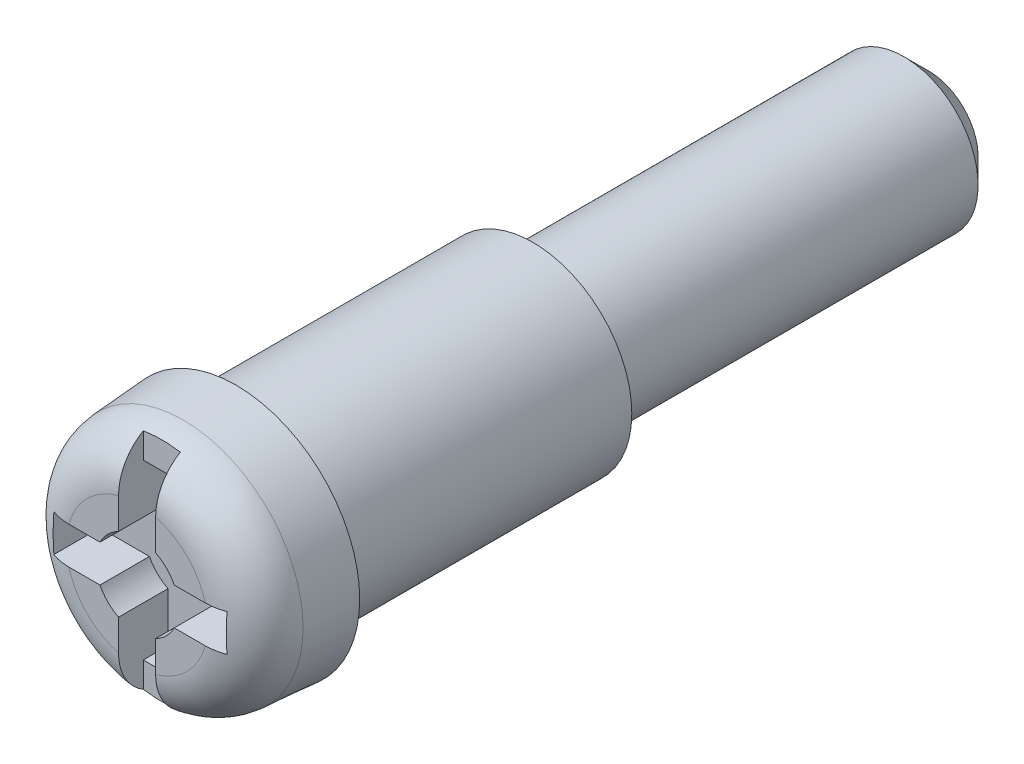
from build123d import *

# Parameters (mm, degrees)
ESQUISSE1_R             = 2.5
BASE_EXTRUSION_DEPTH    = 2
BASE_EXTRUSION_TAPER    = 4
CONG_1_R                = 1
ESQUISSE2_R             = 2
BOSS_EXTRU_1_DEPTH      = 6
ESQUISSE3_R             = 1.5
BOSS_EXTRU_2_DEPTH      = 8
CHANFREIN1_SIZE         = 0.5
ENL_V_MAT_EXTRU_1_DEPTH = 1
ESQUISSE5_W             = 0.75
ESQUISSE5_H             = 5.593358395
ENL_V_MAT_EXTRU_2_DEPTH = 0.5


with BuildPart() as part:
    # Esquisse1 → Base-Extrusion (new body)
    with BuildSketch(Plane.XY):
        Circle(ESQUISSE1_R)
    extrude(amount=BASE_EXTRUSION_DEPTH, taper=BASE_EXTRUSION_TAPER)

    # Congé1
    cong_1_edges = [part.edges().sort_by_distance(p)[0] for p in [
        (-2.360146376, 0, 2),
    ]]
    fillet(cong_1_edges, radius=CONG_1_R)

    # Esquisse2 → Boss.-Extru.1 (add)
    with BuildSketch(Plane(origin=(0, 0, 0), x_dir=(-1, 0, 0), z_dir=(0, 0, -1))):
        Circle(ESQUISSE2_R)
    extrude(amount=BOSS_EXTRU_1_DEPTH)

    # Esquisse3 → Boss.-Extru.2 (add)
    with BuildSketch(Plane(origin=(0, 0, -6), x_dir=(-1, 0, 0), z_dir=(0, 0, -1))):
        Circle(ESQUISSE3_R)
    extrude(amount=BOSS_EXTRU_2_DEPTH)

    # Chanfrein1
    chanfrein1_edges = [part.edges().sort_by_distance(p)[0] for p in [
        (1.5, 0, -14),
    ]]
    chamfer(chanfrein1_edges, length=CHANFREIN1_SIZE)

    # Esquisse4 → Enlèv. mat.-Extru.1 (cut)
    with BuildSketch(Plane.XY.offset(2)):
        with BuildLine():
            Line((-1.75, -0.375), (-0.75, -0.375))
            ThreePointArc((-0.75, -0.375), (-0.592927061, -0.592927061), (-0.375, -0.75))
            Line((-0.375, -0.75), (-0.375, -1.75))
            Line((-0.375, -1.75), (0.375, -1.75))
            Line((0.375, -1.75), (0.375, -0.75))
            ThreePointArc((0.375, -0.75), (0.592927061, -0.592927061), (0.75, -0.375))
            Line((0.75, -0.375), (1.75, -0.375))
            Line((1.75, -0.375), (1.75, 0.375))
            Line((1.75, 0.375), (0.75, 0.375))
            ThreePointArc((0.75, 0.375), (0.592927061, 0.592927061), (0.375, 0.75))
            Line((0.375, 0.75), (0.375, 1.75))
            Line((0.375, 1.75), (-0.375, 1.75))
            Line((-0.375, 1.75), (-0.375, 0.75))
            ThreePointArc((-0.375, 0.75), (-0.592927061, 0.592927061), (-0.75, 0.375))
            Line((-0.75, 0.375), (-1.75, 0.375))
            Line((-1.75, 0.375), (-1.75, -0.375))
        make_face()
    extrude(amount=-ENL_V_MAT_EXTRU_1_DEPTH, mode=Mode.SUBTRACT)

    # Esquisse5 → Enlèv. mat.-Extru.2 (cut)
    with BuildSketch(Plane.XY.offset(2)):
        with Locations((0, -0.203384651)):
            Rectangle(ESQUISSE5_W, ESQUISSE5_H)
    extrude(amount=-ENL_V_MAT_EXTRU_2_DEPTH, mode=Mode.SUBTRACT)


solid = part.part
